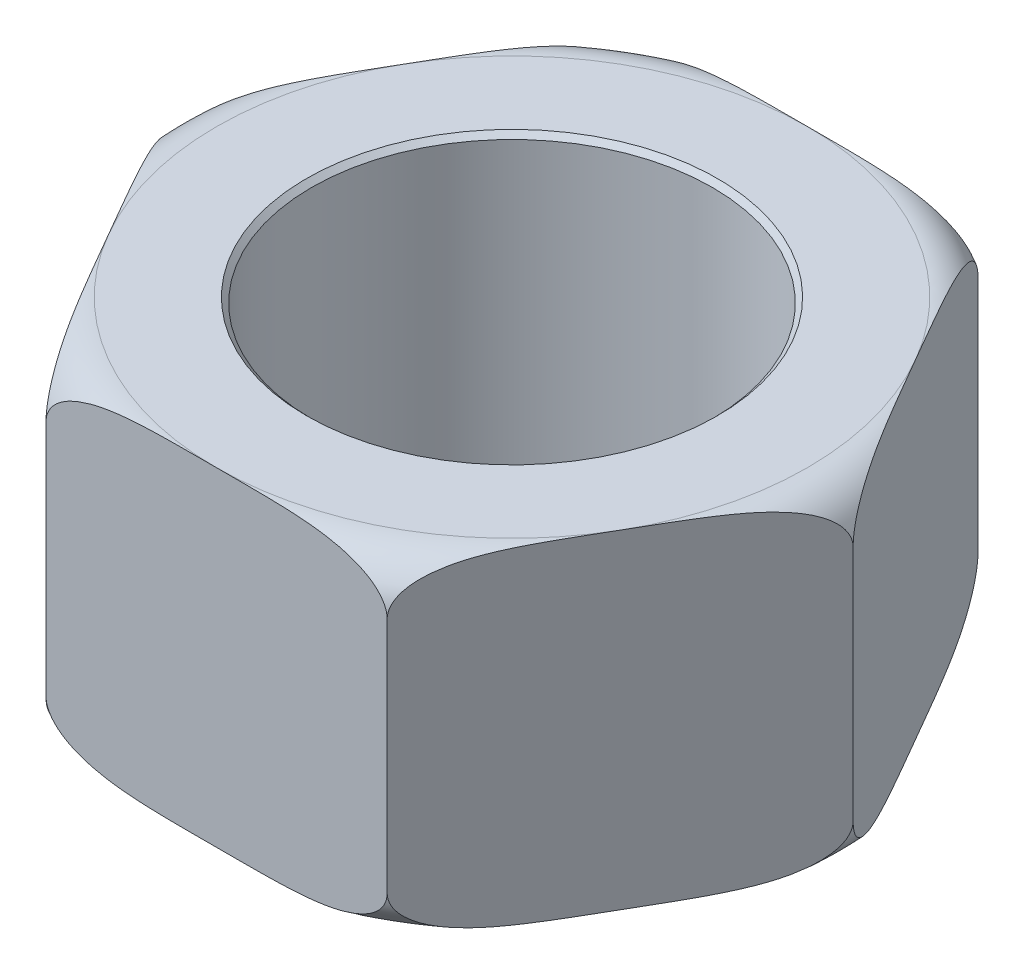
from build123d import *

# Parameters (mm, degrees)
BOSS_EXTRUDE1_DEPTH = 64
SKETCH6_R           = 78
CUT_EXTRUDE1_DEPTH  = 129.000000101
CHAMFER1_SIZE       = 2


with BuildPart() as part:
    # Sketch1 → Boss-Extrude1 (new body, symmetric)
    with BuildSketch(Plane(origin=(0, 0, 0), x_dir=(1, 0, 0), z_dir=(0, 1, 0))):
        Polygon((132.790561914, 0), (66.395280957, 115), (-66.395280957, 115), (-132.790561914, 0), (-66.395280957, -115), (66.395280957, -115), align=None)
    extrude(amount=BOSS_EXTRUDE1_DEPTH, both=True)

    # Sketch3 → Cut-Revolve1 (revolve, cut)
    with BuildSketch(Plane.XY):
        with BuildLine():
            Line((-132.790561914, 64), (-132.790561914, 46.209438086))
            ThreePointArc((-132.790561914, 46.209438086), (-127.57982697, 58.789265057), (-115, 64))
            Line((-115, 64), (-132.790561914, 64))
        make_face()
    cut_revolve1 = revolve(axis=Axis((0, -11.068960952, 0), (0, -1, 0)), mode=Mode.SUBTRACT)

    # Mirror1: Cut-Revolve1 across plane
    add(cut_revolve1.mirror(Plane.ZX), mode=Mode.SUBTRACT)

    # Sketch6 → Cut-Extrude1 (cut, through all)
    with BuildSketch(Plane(origin=(0, 64, 0), x_dir=(1, 0, 0), z_dir=(0, 1, 0))):
        Circle(SKETCH6_R)
    extrude(amount=-CUT_EXTRUDE1_DEPTH, mode=Mode.SUBTRACT)

    # Chamfer1
    chamfer1_edges = [part.edges().sort_by_distance(p)[0] for p in [
        (-78, -64, 0),
        (-78, 64, 0),
    ]]
    chamfer(chamfer1_edges, length=CHAMFER1_SIZE)


solid = part.part
